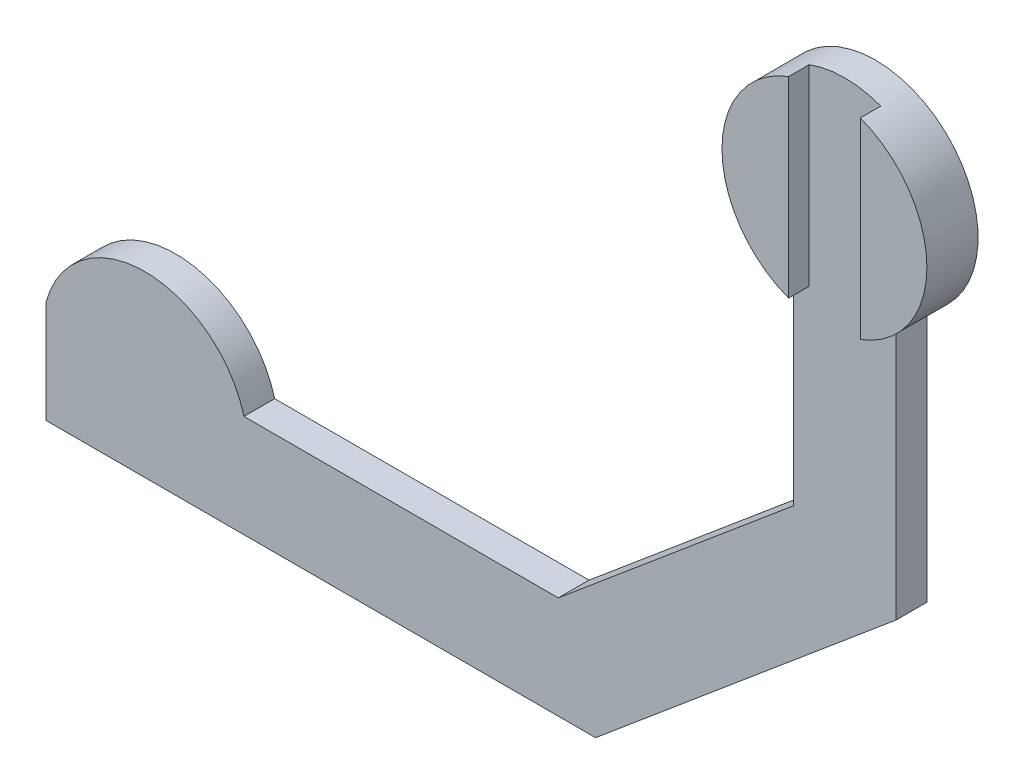
from build123d import *

# Parameters (mm, degrees)
SKETCH2_R           = 10
BOSS_EXTRUDE1_DEPTH = 3
BOSS_EXTRUDE2_DEPTH = 3
BOSS_EXTRUDE3_DEPTH = 3
BOSS_EXTRUDE7_DEPTH = 2


with BuildPart() as part:
    # Sketch2 → Boss-Extrude1 (new body)
    with BuildSketch(Plane.XY):
        Circle(SKETCH2_R)
    extrude(amount=BOSS_EXTRUDE1_DEPTH)

    # Sketch3 → Boss-Extrude2 (add)
    with BuildSketch(Plane.XY.offset(3)):
        Polygon((-5, -8.660254038), (5, -8.660254038), (5, -33.323330619), (-24.341630951, -57.943882328), (-77.981333294, -57.943882328), (-77.981333294, -47.943882328), (-27.981333294, -47.943882328), (-5, -28.660254038), align=None)
    extrude(amount=-BOSS_EXTRUDE2_DEPTH)

    # Sketch4 → Boss-Extrude3 (add)
    with BuildSketch(Plane.XY.offset(3)):
        with BuildLine():
            Line((-77.981333294, -47.943882328), (-58.662816768, -47.943882328))
            ThreePointArc((-58.662816768, -47.943882328), (-68.322075031, -40.532072779), (-77.981333294, -47.943882328))
        make_face()
    extrude(amount=-BOSS_EXTRUDE3_DEPTH)

    # Sketch5 → Boss-Extrude7 (add)
    with BuildSketch(Plane.XY.offset(3)):
        with BuildLine():
            Line((-3.5, -9.367496998), (-3.5, 9.367496998))
            ThreePointArc((-3.5, 9.367496998), (-9.965563298, 0.829185233), (-5, -8.660254038))
            ThreePointArc((-5, -8.660254038), (-4.264686173, -9.045023596), (-3.5, -9.367496998))
        make_face()
        with BuildLine():
            ThreePointArc((5, -8.660254038), (9.965563298, 0.829185233), (3.5, 9.367496998))
            Line((3.5, 9.367496998), (3.5, -9.367496998))
            ThreePointArc((3.5, -9.367496998), (4.264686173, -9.045023596), (5, -8.660254038))
        make_face()
    extrude(amount=BOSS_EXTRUDE7_DEPTH)


solid = part.part
